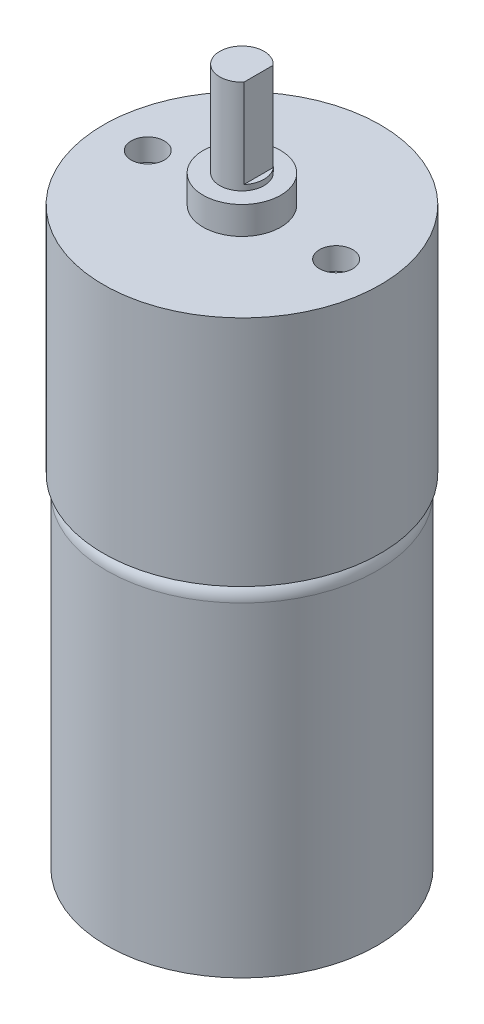
from build123d import *

# Parameters (mm, degrees)
ODEBRAT_VYSUNUT_M1_DEPTH = 8
SKICA3_R                 = 1.5
ODEBRAT_VYSUNUT_M2_DEPTH = 2


with BuildPart() as part:
    # Skica1 → Rotovat1 (revolve)
    with BuildSketch(Plane.XY):
        with BuildLine():
            Line((0, 0), (3.25, 0))
            Line((3.25, 0), (3.25, 2))
            Line((3.25, 2), (12.2, 2))
            Line((12.2, 2), (12.2, 31.3))
            ThreePointArc((12.2, 31.3), (11.760660172, 32.360660172), (10.7, 32.8))
            Line((10.7, 32.8), (12.5, 32.8))
            Line((12.5, 32.8), (12.5, 53.8))
            Line((12.5, 53.8), (3.5, 53.8))
            Line((3.5, 53.8), (3.5, 56.3))
            Line((3.5, 56.3), (2, 56.3))
            Line((2, 56.3), (2, 64.8))
            Line((2, 64.8), (0, 64.8))
            Line((0, 64.8), (0, 0))
        make_face()
    revolve(axis=Axis((0, 0, 0), (0, 1, 0)))

    # Skica2 → Odebrat vysunutím1 (cut)
    with BuildSketch(Plane(origin=(0, 64.8, 0), x_dir=(1, 0, 0), z_dir=(0, 1, 0))):
        with BuildLine():
            Line((1.5, 1.322875656), (1.5, -1.322875656))
            ThreePointArc((1.5, -1.322875656), (2, 0), (1.5, 1.322875656))
        make_face()
    extrude(amount=-ODEBRAT_VYSUNUT_M1_DEPTH, mode=Mode.SUBTRACT)

    # Skica3 → Odebrat vysunutím2 (cut)
    with BuildSketch(Plane(origin=(0, 53.8, 0), x_dir=(1, 0, 0), z_dir=(0, 1, 0))):
        with Locations((8.5, 0)):
            Circle(SKICA3_R)
        with Locations((-8.5, 0)):
            Circle(SKICA3_R)
    extrude(amount=-ODEBRAT_VYSUNUT_M2_DEPTH, mode=Mode.SUBTRACT)


solid = part.part
